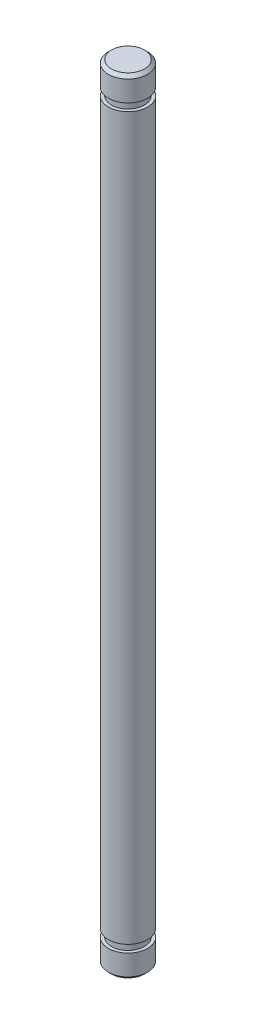
from build123d import *

# Parameters (mm, degrees)
SKETCH1_R      = 0.79375
EXTRUDE1_DEPTH = 15.875
SKETCH2_W      = 0.127
SKETCH2_H      = 0.3048
CHAMFER1_SIZE  = 0.127


with BuildPart() as part:
    # Sketch1 → Extrude1 (new, symmetric)
    with BuildSketch(Plane(origin=(0, 0, 0), x_dir=(1, 0, 0), z_dir=(0, 1, 0))):
        with Locations(Location((0, 0, 0), (0, 0, 270))):
            Circle(SKETCH1_R)
    extrude(amount=EXTRUDE1_DEPTH, both=True)

    # Sketch2 → Cut-Revolve1 (revolve, cut)
    with BuildSketch(Plane(origin=(0, 0, 0), x_dir=(0, 0, -1), z_dir=(1, 0, 0)), mode=Mode.PRIVATE) as cut_revolve1_sk:
        with Locations((0.73025, 14.7574)):
            Rectangle(SKETCH2_W, SKETCH2_H)
        with Locations((0.73025, -14.7574)):
            Rectangle(SKETCH2_W, SKETCH2_H)
    revolve(cut_revolve1_sk.sketch.rotate(Axis((0, 15.875, 0), (0, -1, 0)), 180), axis=Axis((0, 15.875, 0), (0, -1, 0)), mode=Mode.SUBTRACT)

    # Chamfer1
    chamfer1_edges = [part.edges().sort_by_distance(p)[0] for p in [
        (0, -15.875, -0.79375),
        (0, 15.875, -0.79375),
    ]]
    chamfer(chamfer1_edges, length=CHAMFER1_SIZE)


solid = part.part
